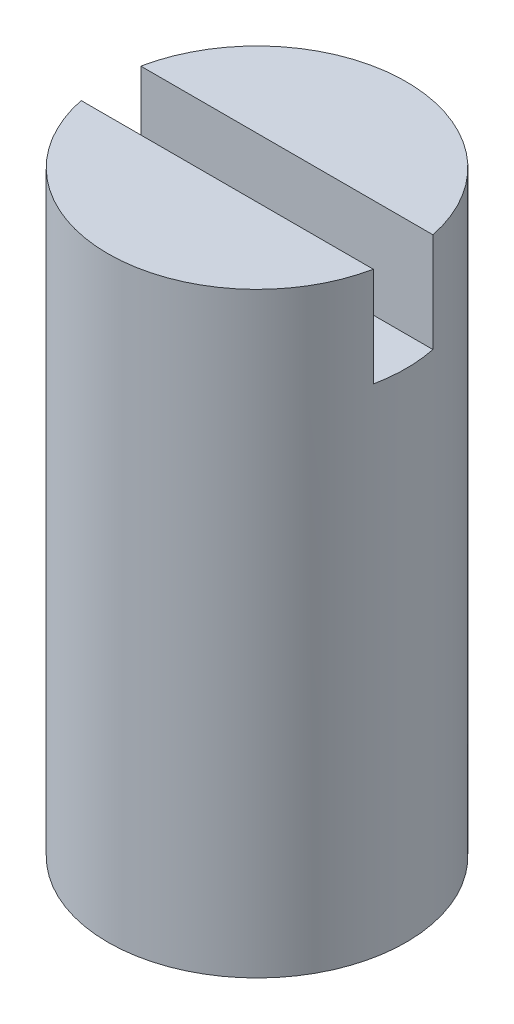
from build123d import *

# Parameters (mm, degrees)
SKETCH1_R           = 4.7625
BOSS_EXTRUDE1_DEPTH = 19.05
SKETCH2_W           = 9.525
SKETCH2_H           = 1.905
CUT_EXTRUDE1_DEPTH  = 3.175
SKETCH3_R           = 2
CUT_EXTRUDE2_DEPTH  = 8


with BuildPart() as part:
    # Sketch1 → Boss-Extrude1 (new body)
    with BuildSketch(Plane(origin=(0, 0, 0), x_dir=(1, 0, 0), z_dir=(0, 1, 0))):
        Circle(SKETCH1_R)
    extrude(amount=-BOSS_EXTRUDE1_DEPTH)

    # Sketch2 → Cut-Extrude1 (cut)
    with BuildSketch(Plane(origin=(0, 0, 0), x_dir=(1, 0, 0), z_dir=(0, 1, 0))):
        Rectangle(SKETCH2_W, SKETCH2_H)
    extrude(amount=-CUT_EXTRUDE1_DEPTH, mode=Mode.SUBTRACT)

    # Sketch3 → Cut-Extrude2 (cut)
    with BuildSketch(Plane.XZ.offset(19.05)):
        Circle(SKETCH3_R)
    extrude(amount=-CUT_EXTRUDE2_DEPTH, mode=Mode.SUBTRACT)


solid = part.part
